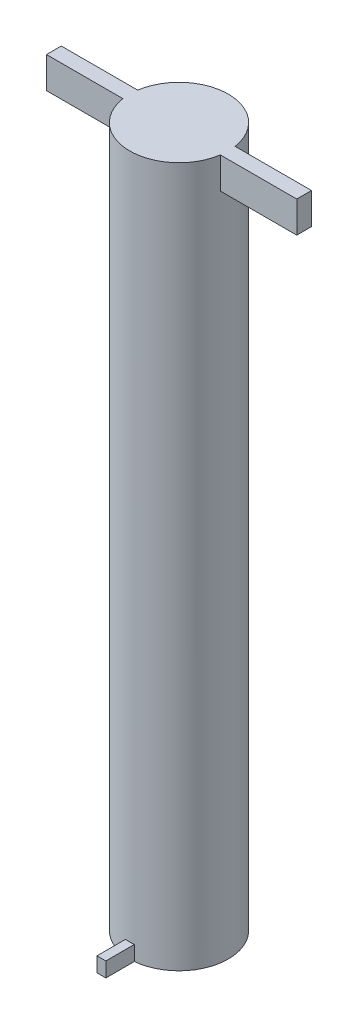
from build123d import *

# Parameters (mm, degrees)
SKETCH1_R           = 10
BOSS_EXTRUDE1_DEPTH = 142.050008
BOSS_EXTRUDE2_DEPTH = 3
SKETCH4_W           = 50.8
SKETCH4_H           = 3
BOSS_EXTRUDE3_DEPTH = 6.35
SKETCH5_R           = 6
CUT_EXTRUDE1_DEPTH  = 3


with BuildPart() as part:
    # Sketch1 → Boss-Extrude1 (new body)
    with BuildSketch(Plane(origin=(0, 0, 0), x_dir=(1, 0, 0), z_dir=(0, 1, 0))):
        Circle(SKETCH1_R)
    extrude(amount=BOSS_EXTRUDE1_DEPTH)

    # Sketch3 → Boss-Extrude2 (add)
    with BuildSketch(Plane.XZ):
        with BuildLine():
            Line((-0.9, 15.75), (0.9, 15.75))
            Line((0.9, 15.75), (0.9, 9.354806465))
            ThreePointArc((0.9, 9.354806465), (0, 9.398), (-0.9, 9.354806465))
            Line((-0.9, 9.354806465), (-0.9, 15.75))
        make_face()
    extrude(amount=-BOSS_EXTRUDE2_DEPTH)

    # Sketch4 → Boss-Extrude3 (add)
    with BuildSketch(Plane(origin=(0, 142.050008, 0), x_dir=(1, 0, 0), z_dir=(0, 1, 0))):
        Rectangle(SKETCH4_W, SKETCH4_H)
    extrude(amount=-BOSS_EXTRUDE3_DEPTH)

    # Sketch5 → Cut-Extrude1 (cut)
    with BuildSketch(Plane.XZ):
        Circle(SKETCH5_R)
    extrude(amount=-CUT_EXTRUDE1_DEPTH, mode=Mode.SUBTRACT)


solid = part.part
